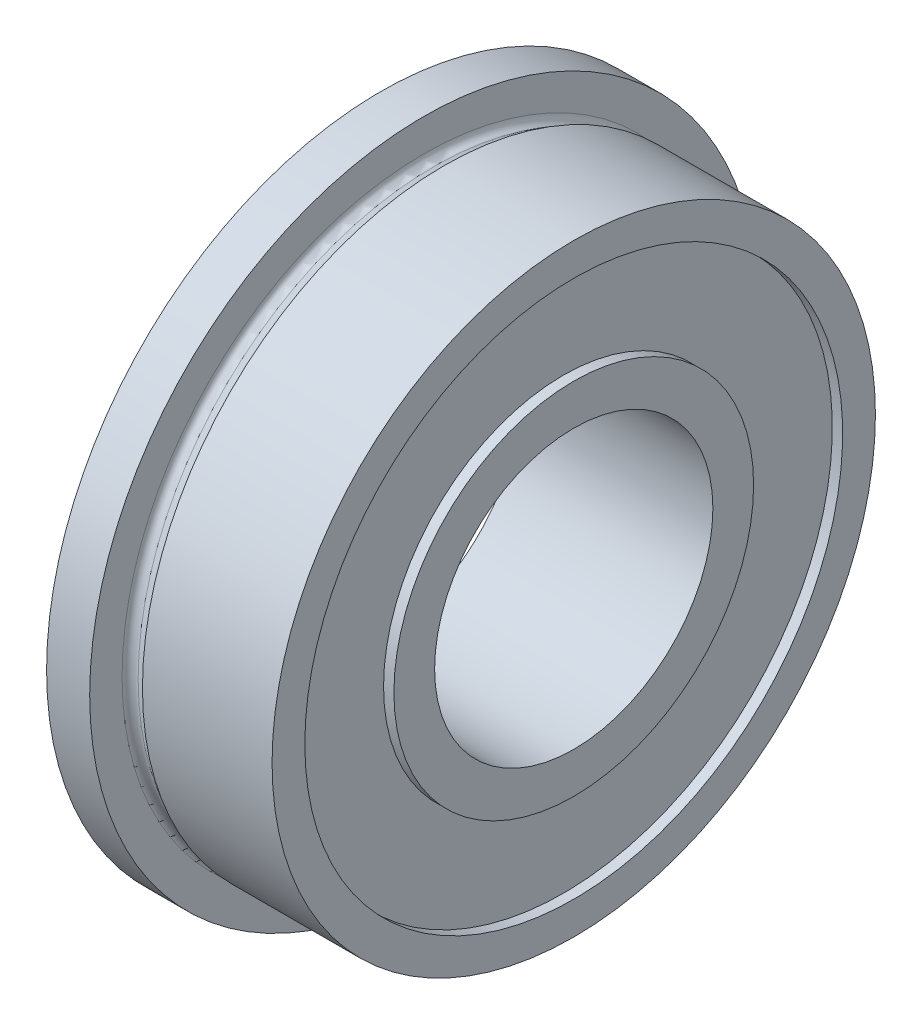
from build123d import *


with BuildPart() as part:
    # Sketch1 → Revolve1 (revolve)
    with BuildSketch(Plane(origin=(0, 0, 0), x_dir=(-1, 0, 0), z_dir=(0, 0, -1))):
        with BuildLine():
            Line((-2.3375, 11.1125), (-7.112, 11.1125))
            Line((-7.112, 11.1125), (-7.112, 9.906))
            Line((-7.112, 9.906), (-6.731, 9.906))
            Line((-6.731, 9.906), (-6.731, 6.625))
            Line((-6.731, 6.625), (-7.112, 6.625))
            Line((-7.112, 6.625), (-7.112, 5.125))
            Line((-7.112, 5.125), (0, 5.125))
            Line((0, 5.125), (0, 6.625))
            Line((0, 6.625), (-0.381, 6.625))
            Line((-0.381, 6.625), (-0.381, 9.906))
            Line((-0.381, 9.906), (0, 9.906))
            Line((0, 9.906), (0, 12.3063))
            Line((0, 12.3063), (-1.5875, 12.3063))
            Line((-1.5875, 12.3063), (-1.5875, 11.1125))
            ThreePointArc((-1.5875, 11.1125), (-1.7125, 10.895993649), (-1.9625, 10.895993649))
            Line((-1.9625, 10.895993649), (-2.3375, 11.1125))
        make_face()
    revolve(axis=Axis((7.112, 0, 0), (-1, 0, 0)))


solid = part.part
